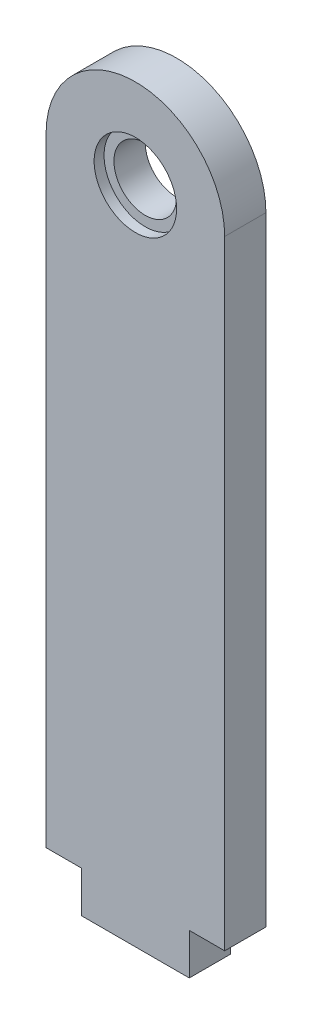
from build123d import *

# Parameters (mm, degrees)
SKETCH1_R           = 4.826
SKETCH1_W           = 16.600988984
SKETCH1_H           = 6.35
BOSS_EXTRUDE1_DEPTH = 6.35
SKETCH2_R           = 6.35
SKETCH2_R_2         = 4.826
CUT_EXTRUDE1_DEPTH  = 1.524


with BuildPart() as part:
    # Sketch1 → Boss-Extrude1 (new body)
    with BuildSketch(Plane.XY):
        with BuildLine():
            Line((0, 0), (27.5, 0))
            Line((27.5, 0), (27.5, 95.25))
            ThreePointArc((27.5, 95.25), (13.75, 109), (0, 95.25))
            Line((0, 95.25), (0, 0))
        make_face()
        with Locations((13.75, 95.25)):
            Circle(SKETCH1_R, mode=Mode.SUBTRACT)
        with Locations((13.75, -3.175)):
            Rectangle(SKETCH1_W, SKETCH1_H)
    extrude(amount=BOSS_EXTRUDE1_DEPTH)

    # Sketch2 → Cut-Extrude1 (cut)
    with BuildSketch(Plane.XY.offset(6.35)):
        with Locations((13.75, 95.25)):
            Circle(SKETCH2_R)
        with Locations((13.75, 95.25)):
            Circle(SKETCH2_R_2, mode=Mode.SUBTRACT)
    extrude(amount=-CUT_EXTRUDE1_DEPTH, mode=Mode.SUBTRACT)


solid = part.part
